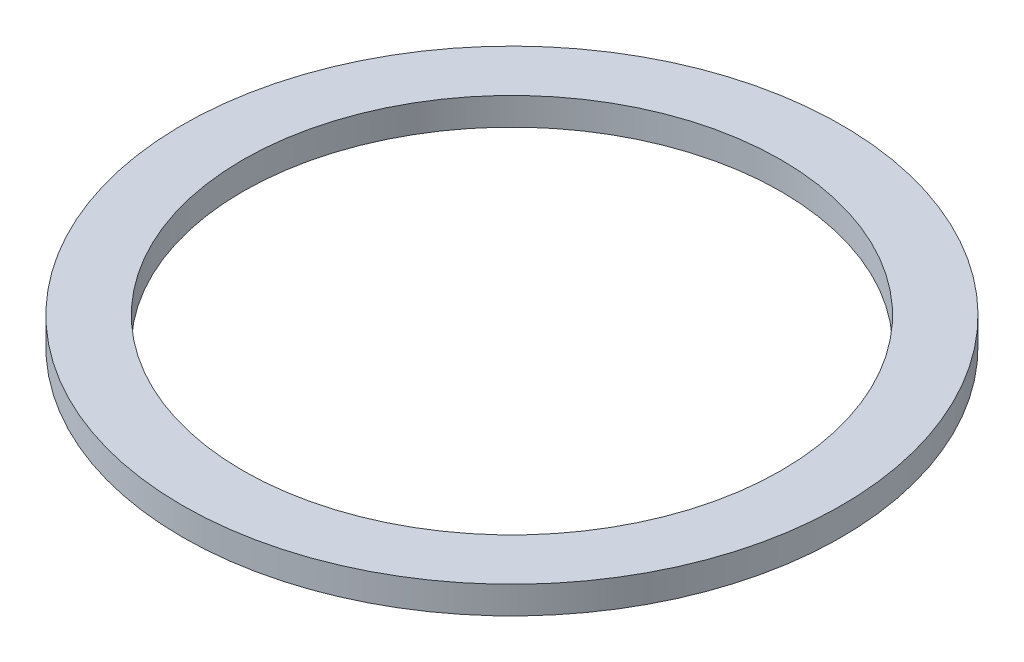
from build123d import *

# Parameters (mm, degrees)
SKETCH1_R           = 120
SKETCH1_R_2         = 98
BOSS_EXTRUDE1_DEPTH = 10
SKETCH2_R           = 3


with BuildPart() as part:
    # Sketch1 → Boss-Extrude1 (new body)
    with BuildSketch(Plane(origin=(0, 0, 0), x_dir=(1, 0, 0), z_dir=(0, 1, 0))):
        Circle(SKETCH1_R)
        Circle(SKETCH1_R_2, mode=Mode.SUBTRACT)
    extrude(amount=BOSS_EXTRUDE1_DEPTH)

    # Sketch2 → Cut-Revolve1 (revolve, cut)
    with BuildSketch(Plane.XY):
        with Locations((110, -1)):
            Circle(SKETCH2_R)
    revolve(axis=Axis((0, 0, 0), (0, 1, 0)), mode=Mode.SUBTRACT)


solid = part.part
